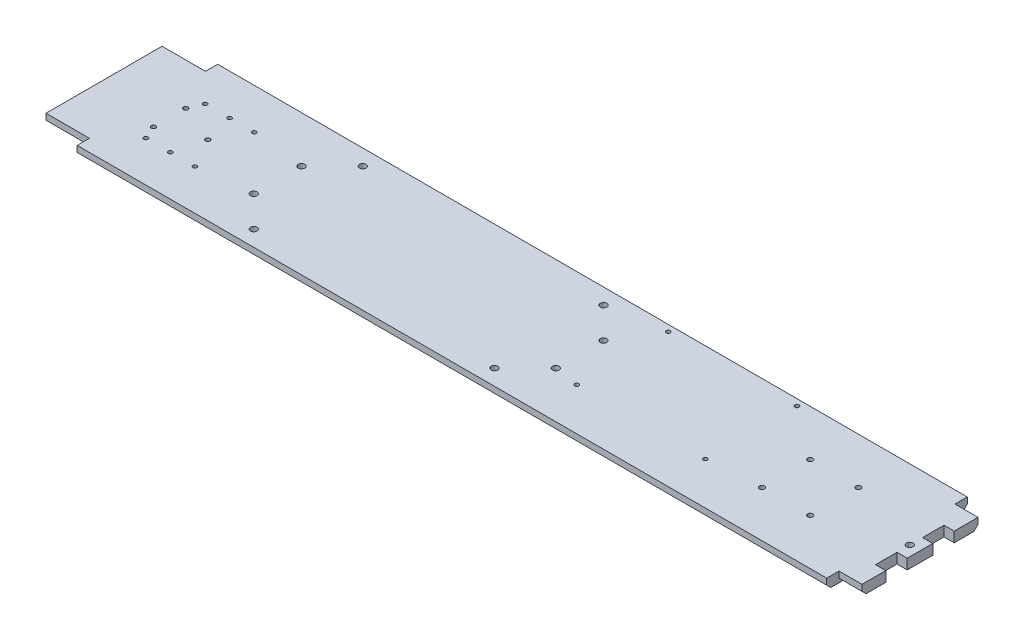
from build123d import *

# Parameters (mm, degrees)
SKETCH1_W           = 520.0000014
SKETCH1_H           = 87.376
BOSS_EXTRUDE1_DEPTH = 6.35
SKETCH3_W           = 27
SKETCH3_H           = 7.62
CUT_EXTRUDE2_DEPTH  = 7.35
SKETCH6_W           = 12.7
SKETCH6_H           = 72.136
CUT_EXTRUDE5_DEPTH  = 7.35
CHAMFER1_SIZE       = 2.54
SKETCH8_R           = 1.4
CUT_EXTRUDE7_DEPTH  = 7.35
SKETCH9_R           = 2.0499959
CUT_EXTRUDE8_DEPTH  = 7.35
SKETCH10_R          = 1.27
CUT_EXTRUDE9_DEPTH  = 7.35
SKETCH11_R          = 2.05
CUT_EXTRUDE10_DEPTH = 7.35
SKETCH12_R          = 1.27
CUT_EXTRUDE11_DEPTH = 7.35
SKETCH13_W          = 6.35
SKETCH13_H          = 13.335
CUT_EXTRUDE12_DEPTH = 7.35
SKETCH14_R          = 1.6
CUT_EXTRUDE13_DEPTH = 7.35


with BuildPart() as part:
    # Sketch1 → Boss-Extrude1 (new body)
    with BuildSketch(Plane(origin=(0, 0, 0), x_dir=(1, 0, 0), z_dir=(0, 1, 0))):
        Rectangle(SKETCH1_W, SKETCH1_H)
    extrude(amount=BOSS_EXTRUDE1_DEPTH)

    # Sketch3 → Cut-Extrude2 (cut, through all)
    with BuildSketch(Plane(origin=(0, 6.35, 0), x_dir=(1, 0, 0), z_dir=(0, 1, 0))):
        with Locations((-246.5000007, 39.878)):
            Rectangle(SKETCH3_W, SKETCH3_H)
        with Locations((-246.5000007, -39.878)):
            Rectangle(SKETCH3_W, SKETCH3_H)
        with Locations((246.5000007, -39.878)):
            Rectangle(SKETCH3_W, SKETCH3_H)
        with Locations((246.5000007, 39.878)):
            Rectangle(SKETCH3_W, SKETCH3_H)
    extrude(amount=-CUT_EXTRUDE2_DEPTH, mode=Mode.SUBTRACT)

    # Sketch6 → Cut-Extrude5 (cut, through all)
    with BuildSketch(Plane(origin=(0, 6.35, 0), x_dir=(1, 0, 0), z_dir=(0, 1, 0))):
        with Locations((253.6500007, 0)):
            Rectangle(SKETCH6_W, SKETCH6_H)
    extrude(amount=-CUT_EXTRUDE5_DEPTH, mode=Mode.SUBTRACT)

    # Chamfer1
    chamfer1_edges = [part.edges().sort_by_distance(p)[0] for p in [
        (0, 0, -43.688),
        (0, 0, 43.688),
        (240.1500007, 0, -36.068),
        (-246.5000007, 0, 36.068),
        (-246.5000007, 0, -36.068),
        (240.1500007, 0, 36.068),
    ]]
    chamfer(chamfer1_edges, length=CHAMFER1_SIZE)

    # Sketch8 → Cut-Extrude7 (cut, through all)
    with BuildSketch(Plane(origin=(0, 6.35, 0), x_dir=(1, 0, 0), z_dir=(0, 1, 0))):
        with Locations((-219.2000007, 10)):
            Circle(SKETCH8_R)
        with Locations((-219.2000007, -10)):
            Circle(SKETCH8_R)
        with Locations((-195.5000007, 0)):
            Circle(SKETCH8_R)
    extrude(amount=-CUT_EXTRUDE7_DEPTH, mode=Mode.SUBTRACT)

    # Sketch9 → Cut-Extrude8 (cut, through all)
    with BuildSketch(Plane(origin=(0, 6.35, 0), x_dir=(1, 0, 0), z_dir=(0, 1, 0))):
        with Locations((-133.0000007, 33.89)):
            Circle(SKETCH9_R)
        with Locations((-152.0500007, 14.84)):
            Circle(SKETCH9_R)
        with Locations((-152.0500007, -14.84)):
            Circle(SKETCH9_R)
        with Locations((-133.0000007, -33.89)):
            Circle(SKETCH9_R)
        with Locations((16.6799993, 33.89)):
            Circle(SKETCH9_R)
        with Locations((35.7299993, 14.84)):
            Circle(SKETCH9_R)
        with Locations((35.7299993, -14.84)):
            Circle(SKETCH9_R)
        with Locations((16.6799993, -33.89)):
            Circle(SKETCH9_R)
    extrude(amount=-CUT_EXTRUDE8_DEPTH, mode=Mode.SUBTRACT)

    # Sketch10 → Cut-Extrude9 (cut, through all)
    with BuildSketch(Plane(origin=(0, 6.35, 0), x_dir=(1, 0, 0), z_dir=(0, 1, 0))):
        with Locations((-200.3100007, -18.415)):
            Circle(SKETCH10_R)
        with Locations((-215.5500007, -18.415)):
            Circle(SKETCH10_R)
        with Locations((-200.3100007, 18.415)):
            Circle(SKETCH10_R)
        with Locations((-215.5500007, 18.415)):
            Circle(SKETCH10_R)
        with Locations((-185.0700007, 18.415)):
            Circle(SKETCH10_R)
        with Locations((-185.0700007, -18.415)):
            Circle(SKETCH10_R)
    extrude(amount=-CUT_EXTRUDE9_DEPTH, mode=Mode.SUBTRACT)

    # Sketch11 → Cut-Extrude10 (cut, through all)
    with BuildSketch(Plane(origin=(0, 6.35, 0), x_dir=(1, 0, 0), z_dir=(0, 1, 0))):
        with Locations((240.9500007, 0)):
            Circle(SKETCH11_R)
    extrude(amount=-CUT_EXTRUDE10_DEPTH, mode=Mode.SUBTRACT)

    # Sketch12 → Cut-Extrude11 (cut, through all)
    with BuildSketch(Plane(origin=(0, 6.35, 0), x_dir=(1, 0, 0), z_dir=(0, 1, 0))):
        with Locations((51.1499993, 39.688)):
            Circle(SKETCH12_R)
        with Locations((131.1499993, 39.688)):
            Circle(SKETCH12_R)
        with Locations((51.1499993, -17.312)):
            Circle(SKETCH12_R)
        with Locations((131.1499993, -17.312)):
            Circle(SKETCH12_R)
    extrude(amount=-CUT_EXTRUDE11_DEPTH, mode=Mode.SUBTRACT)

    # Sketch13 → Cut-Extrude12 (cut, through all)
    with BuildSketch(Plane(origin=(0, 6.35, 0), x_dir=(1, 0, 0), z_dir=(0, 1, 0))):
        with Locations((244.1250007, -14.605)):
            Rectangle(SKETCH13_W, SKETCH13_H)
        with Locations((244.1250007, 14.605)):
            Rectangle(SKETCH13_W, SKETCH13_H)
    extrude(amount=-CUT_EXTRUDE12_DEPTH, mode=Mode.SUBTRACT)

    # Sketch14 → Cut-Extrude13 (cut, through all)
    with BuildSketch(Plane(origin=(0, 6.35, 0), x_dir=(1, 0, 0), z_dir=(0, 1, 0))):
        with Locations((164.0529993, 15)):
            Circle(SKETCH14_R)
        with Locations((194.0529993, 15)):
            Circle(SKETCH14_R)
        with Locations((164.0529993, -15)):
            Circle(SKETCH14_R)
        with Locations((194.0529993, -15)):
            Circle(SKETCH14_R)
    extrude(amount=-CUT_EXTRUDE13_DEPTH, mode=Mode.SUBTRACT)


solid = part.part
